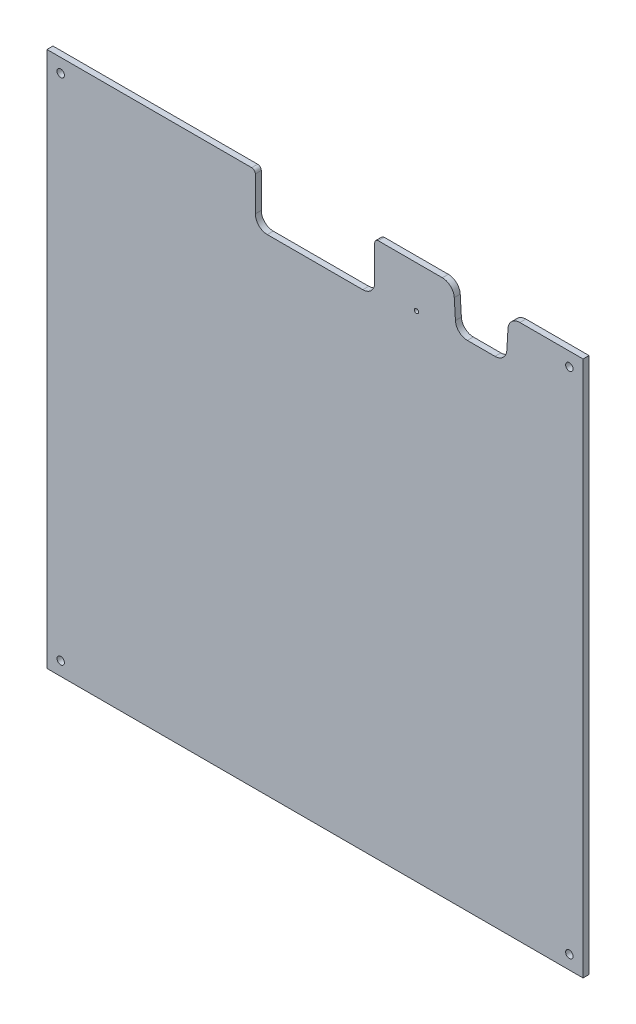
from build123d import *

# Parameters (mm, degrees)
SCHIZZO1_R                   = 3.1
SCHIZZO1_R_2                 = 1.75
ESTRUSIONE_ESTRUSIONE1_DEPTH = 5


with BuildPart() as part:
    # Schizzo1 → Estrusione-Estrusione1 (new body)
    with BuildSketch(Plane.XY):
        with BuildLine():
            Line((0, 0), (0, 449))
            Line((0, 449), (171.5, 449))
            ThreePointArc((171.5, 449), (173.621320344, 448.121320344), (174.5, 446))
            Line((174.5, 446), (174.5, 417))
            ThreePointArc((174.5, 417), (177.428932188, 409.928932188), (184.5, 407))
            Line((184.5, 407), (264.5, 407))
            ThreePointArc((264.5, 407), (271.571067812, 409.928932188), (274.5, 417))
            Line((274.5, 417), (274.5, 446))
            ThreePointArc((274.5, 446), (275.378679656, 448.121320344), (277.5, 449))
            Line((277.5, 449), (331.145963874, 449))
            ThreePointArc((331.145963874, 449), (338.003609857, 446.278234097), (341.128274438, 439.594538314))
            Line((341.128274438, 439.594538314), (342.092482701, 423.405461686))
            ThreePointArc((342.092482701, 423.405461686), (345.217147282, 416.721765903), (352.074793265, 414))
            Line((352.074793265, 414), (375.181755612, 414))
            ThreePointArc((375.181755612, 414), (382.039401595, 416.721765903), (385.164066175, 423.405461686))
            Line((385.164066175, 423.405461686), (386.128274438, 439.594538314))
            ThreePointArc((386.128274438, 439.594538314), (389.252939019, 446.278234097), (396.110585002, 449))
            Line((396.110585002, 449), (449, 449))
            Line((449, 449), (449, 0))
            Line((449, 0), (0, 0))
        make_face()
        with Locations((11.5, 11.5)):
            Circle(SCHIZZO1_R, mode=Mode.SUBTRACT)
        with Locations((437.5, 11.5)):
            Circle(SCHIZZO1_R, mode=Mode.SUBTRACT)
        with Locations((437.5, 437.5)):
            Circle(SCHIZZO1_R, mode=Mode.SUBTRACT)
        with Locations((11.5, 437.5)):
            Circle(SCHIZZO1_R, mode=Mode.SUBTRACT)
        with Locations((309.5, 414)):
            Circle(SCHIZZO1_R_2, mode=Mode.SUBTRACT)
    extrude(amount=ESTRUSIONE_ESTRUSIONE1_DEPTH)


solid = part.part
